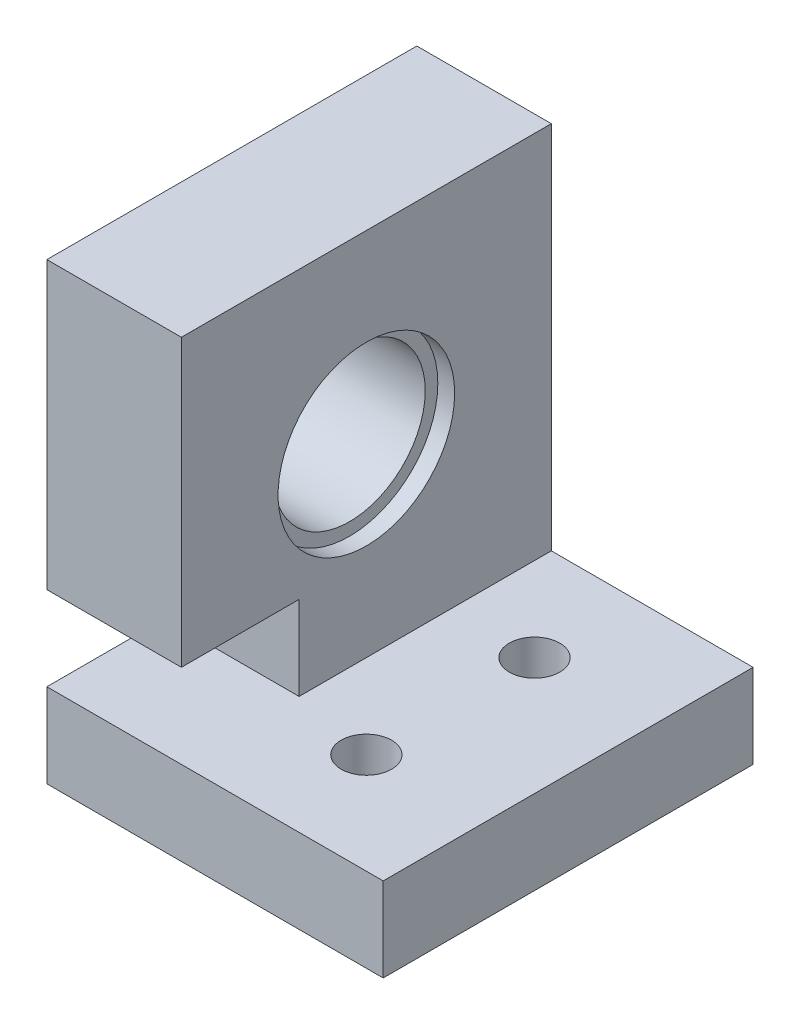
from build123d import *

# Parameters (mm, degrees)
SKETCH_1_W             = 22
SKETCH_1_H             = 30
EXTRUDE_1_DEPTH        = 8
SKETCH_2_R             = 4.5
CUT_EXTRUDE_1_DEPTH    = 9
SKETCH_3_W             = 7
SKETCH_3_H             = 8
CUT_EXTRUDE_2_DEPTH    = 9
SKETCH_4_R             = 5.25
CUT_EXTRUDE_3_DEPTH    = 1
SKETCH_5_R             = 5.25
CUT_EXTRUDE_4_DEPTH    = 1
SKETCH_6_W             = 22
SKETCH_6_H             = 5
EXTRUDE_2_DEPTH        = 12
CUT_EXTRUDE_5_DEPTH    = 2.5
PATTERN_LINEAR_1_COUNT = 2
PATTERN_LINEAR_1_PITCH = 10
SKETCH_8_R             = 1.5
CUT_EXTRUDE_6_DEPTH    = 28.5
PATTERN_LINEAR_2_COUNT = 2
PATTERN_LINEAR_2_PITCH = 10
EXTRUDE_3_DEPTH        = 3
SKETCH_12_R            = 1.5
CUT_EXTRUDE_7_DEPTH    = 26
SKETCH_14_R            = 1.5
CUT_EXTRUDE_8_DEPTH    = 26
CUT_EXTRUDE_9_DEPTH    = 3
PATTERN_LINEAR_3_COUNT = 2
PATTERN_LINEAR_3_PITCH = 10
SKETCH_16_W            = 20
SKETCH_16_H            = 22
CUT_EXTRUDE_10_DEPTH   = 3


with BuildPart() as part:
    # 草图1 → 凸台-拉伸1 (new body)
    with BuildSketch(Plane(origin=(0, 0, 0), x_dir=(0, 0, -1), z_dir=(1, 0, 0))):
        Rectangle(SKETCH_1_W, SKETCH_1_H)
    extrude(amount=EXTRUDE_1_DEPTH)

    # 草图2 → 切除-拉伸1 (cut, through all)
    with BuildSketch(Plane.ZY):
        with Locations((0, 4)):
            Circle(SKETCH_2_R)
    extrude(amount=-CUT_EXTRUDE_1_DEPTH, mode=Mode.SUBTRACT)

    # 草图3 → 切除-拉伸2 (cut, through all)
    with BuildSketch(Plane.ZY):
        with Locations((7.5, -6)):
            Rectangle(SKETCH_3_W, SKETCH_3_H)
    extrude(amount=-CUT_EXTRUDE_2_DEPTH, mode=Mode.SUBTRACT)

    # 草图4 → 切除-拉伸3 (cut)
    with BuildSketch(Plane.ZY):
        with Locations((0, 4)):
            Circle(SKETCH_4_R)
    extrude(amount=-CUT_EXTRUDE_3_DEPTH, mode=Mode.SUBTRACT)

    # 草图5 → 切除-拉伸4 (cut)
    with BuildSketch(Plane(origin=(8, 0, 0), x_dir=(0, 0, -1), z_dir=(1, 0, 0))):
        with Locations((0, 4)):
            Circle(SKETCH_5_R)
    extrude(amount=-CUT_EXTRUDE_4_DEPTH, mode=Mode.SUBTRACT)

    # 草图6 → 凸台-拉伸2 (add)
    with BuildSketch(Plane(origin=(8, 0, 0), x_dir=(0, 0, -1), z_dir=(1, 0, 0))):
        with Locations((0, -12.5)):
            Rectangle(SKETCH_6_W, SKETCH_6_H)
    extrude(amount=EXTRUDE_2_DEPTH)

    # 草图7 → 切除-拉伸5 (cut)
    with BuildSketch(Plane.XZ.offset(15)):
        Polygon((9.8, -5), (11.4, -7.771281292), (14.6, -7.771281292), (16.2, -5), (14.6, -2.228718708), (11.4, -2.228718708), align=None)
    cut_extrude_5 = extrude(amount=-CUT_EXTRUDE_5_DEPTH, mode=Mode.SUBTRACT)

    # 阵列(线性)1: 切除-拉伸5 ×2
    with Locations(*[(0, 0, i * PATTERN_LINEAR_1_PITCH) for i in range(1, PATTERN_LINEAR_1_COUNT)]):
        add(cut_extrude_5, mode=Mode.SUBTRACT)

    # 草图8 → 切除-拉伸6 (cut, through all)
    with BuildSketch(Plane.XZ.offset(12.5)):
        with Locations((13, 5)):
            Circle(SKETCH_8_R)
    cut_extrude_6 = extrude(amount=-CUT_EXTRUDE_6_DEPTH, mode=Mode.SUBTRACT)

    # 阵列(线性)2: 切除-拉伸6 ×2
    with Locations(*[(0, 0, -i * PATTERN_LINEAR_2_PITCH) for i in range(1, PATTERN_LINEAR_2_COUNT)]):
        add(cut_extrude_6, mode=Mode.SUBTRACT)

    # 草图10 → 凸台-拉伸3 (add)
    with BuildSketch(Plane(origin=(0, -10, 0), x_dir=(1, 0, 0), z_dir=(0, 1, 0))):
        Polygon((0, -4), (8, -4), (8, 11), (20, 11), (20, -11), (0, -11), align=None)
    extrude(amount=EXTRUDE_3_DEPTH)

    # 草图12 → 切除-拉伸7 (cut, through all)
    with BuildSketch(Plane.XZ.offset(10)):
        with Locations((13, 5)):
            Circle(SKETCH_12_R)
    extrude(amount=-CUT_EXTRUDE_7_DEPTH, mode=Mode.SUBTRACT)

    # 草图14 → 切除-拉伸8 (cut, through all)
    with BuildSketch(Plane.XZ.offset(10)):
        with Locations((13, -5)):
            Circle(SKETCH_14_R)
    extrude(amount=-CUT_EXTRUDE_8_DEPTH, mode=Mode.SUBTRACT)

    # 草图15 → 切除-拉伸9 (cut)
    with BuildSketch(Plane.XZ.offset(12.5)):
        Polygon((16.2, 5), (14.6, 7.771281292), (11.4, 7.771281292), (9.8, 5), (11.4, 2.228718708), (14.6, 2.228718708), align=None)
    cut_extrude_9 = extrude(amount=-CUT_EXTRUDE_9_DEPTH, mode=Mode.SUBTRACT)

    # 阵列(线性)3: 切除-拉伸9 ×2
    with Locations(*[(0, 0, -i * PATTERN_LINEAR_3_PITCH) for i in range(1, PATTERN_LINEAR_3_COUNT)]):
        add(cut_extrude_9, mode=Mode.SUBTRACT)

    # 草图16 → 切除-拉伸10 (cut)
    with BuildSketch(Plane.XZ.offset(15)):
        with Locations((10, 0)):
            Rectangle(SKETCH_16_W, SKETCH_16_H)
    extrude(amount=-CUT_EXTRUDE_10_DEPTH, mode=Mode.SUBTRACT)


solid = part.part
